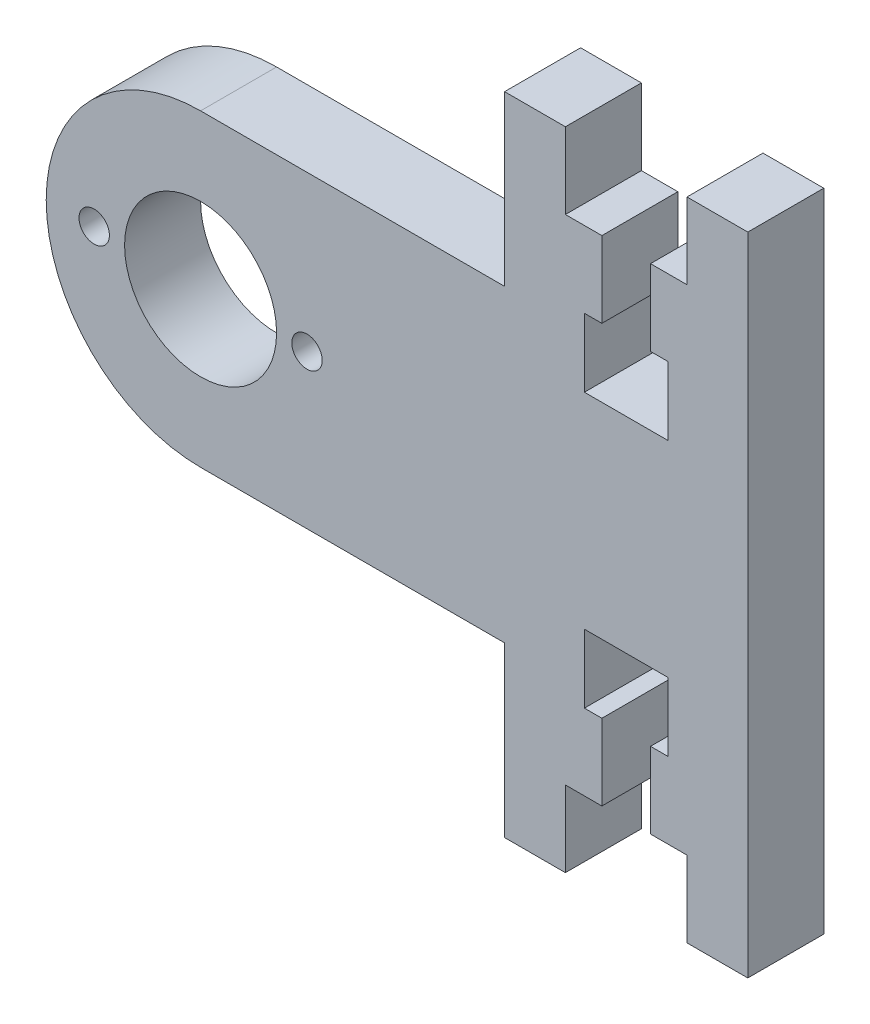
from build123d import *

# Parameters (mm, degrees)
BOSS_EXTRUDE1_DEPTH = 5
SKETCH2_R           = 5
SKETCH2_R_2         = 1
CUT_EXTRUDE1_DEPTH  = 10
SKETCH3_R           = 1
SKETCH3_R_2         = 1.440461169
BOSS_EXTRUDE2_DEPTH = 5
CUT_EXTRUDE2_DEPTH  = 10
SKETCH5_W           = 1
SKETCH5_H           = 5
CUT_EXTRUDE3_DEPTH  = 10


with BuildPart() as part:
    # Sketch1 → Boss-Extrude1 (new body)
    with BuildSketch(Plane.XY):
        with BuildLine():
            Line((-16, 31.40625), (-36, 31.40625))
            ThreePointArc((-36, 31.40625), (-46.15625, 21.25), (-36, 11.09375))
            Line((-36, 11.09375), (-16, 11.09375))
            Line((-16, 11.09375), (-16, 5))
            Line((-16, 5), (-16, 0))
            Line((-16, 0), (-11.25390625, 0))
            Line((-11.25390625, 0), (-11, 0))
            Line((-11, 0), (-11, 0.25390625))
            Line((-11, 0.25390625), (-11, 4.82421875))
            Line((-11, 4.82421875), (-11, 5))
            Line((-11, 5), (-10.74609375, 5))
            Line((-10.74609375, 5), (-8.20703125, 5))
            Line((-8.20703125, 5), (-5, 5))
            Line((-5, 5), (-5, 0))
            Line((-5, 0), (0, 0))
            Line((0, 0), (0, 42.5))
            Line((0, 42.5), (-5, 42.5))
            Line((-5, 42.5), (-5, 37.5))
            Line((-5, 37.5), (-8.20703125, 37.5))
            Line((-8.20703125, 37.5), (-10.74609375, 37.5))
            Line((-10.74609375, 37.5), (-11, 37.5))
            Line((-11, 37.5), (-11, 37.67578125))
            Line((-11, 37.67578125), (-11, 42.24609375))
            Line((-11, 42.24609375), (-11, 42.5))
            Line((-11, 42.5), (-11.25390625, 42.5))
            Line((-11.25390625, 42.5), (-16, 42.5))
            Line((-16, 42.5), (-16, 37.5))
            Line((-16, 37.5), (-16, 31.40625))
        make_face()
    extrude(amount=BOSS_EXTRUDE1_DEPTH)

    # Sketch2 → Cut-Extrude1 (cut)
    with BuildSketch(Plane(origin=(0, 0, 0), x_dir=(-1, 0, 0), z_dir=(0, 0, -1))):
        with Locations((36, 21.25)):
            Circle(SKETCH2_R)
        with Locations((43, 21.312454575)):
            Circle(SKETCH2_R_2)
        with Locations((36.062454575, 14.25)):
            Circle(SKETCH2_R_2)
        with Locations((29, 21.187545425)):
            Circle(SKETCH2_R_2)
        with Locations((35.937545425, 28.25)):
            Circle(SKETCH2_R_2)
    extrude(amount=-CUT_EXTRUDE1_DEPTH, mode=Mode.SUBTRACT)

    # Sketch3 → Boss-Extrude2 (add)
    with BuildSketch(Plane(origin=(0, 0, 0), x_dir=(-1, 0, 0), z_dir=(0, 0, -1))):
        with Locations((35.937545425, 28.25)):
            Circle(SKETCH3_R)
        with Locations((36.062454575, 14.25)):
            Circle(SKETCH3_R_2)
    extrude(amount=-BOSS_EXTRUDE2_DEPTH)

    # Sketch4 → Cut-Extrude2 (cut)
    with BuildSketch(Plane.XY.offset(5)):
        Polygon((-9.6, 5), (-6.4, 5), (-6.4, 10), (-5.25, 10), (-5.25, 14.5), (-10.75, 14.5), (-10.75, 10), (-9.6, 10), align=None)
        Polygon((-10.75, 32.5), (-10.75, 28), (-5.25, 28), (-5.25, 32.5), (-6.4, 32.5), (-6.4, 37.5), (-9.6, 37.5), (-9.6, 32.5), align=None)
    extrude(amount=-CUT_EXTRUDE2_DEPTH, mode=Mode.SUBTRACT)

    # Sketch5 → Cut-Extrude3 (cut)
    with BuildSketch(Plane.XY.offset(5)):
        with Locations((-4.5, 2.5)):
            Rectangle(SKETCH5_W, SKETCH5_H)
        with Locations((-11.5, 2.5)):
            Rectangle(SKETCH5_W, SKETCH5_H)
        with Locations((-11.5, 40)):
            Rectangle(SKETCH5_W, SKETCH5_H)
        with Locations((-4.5, 40)):
            Rectangle(SKETCH5_W, SKETCH5_H)
    extrude(amount=-CUT_EXTRUDE3_DEPTH, mode=Mode.SUBTRACT)


solid = part.part
